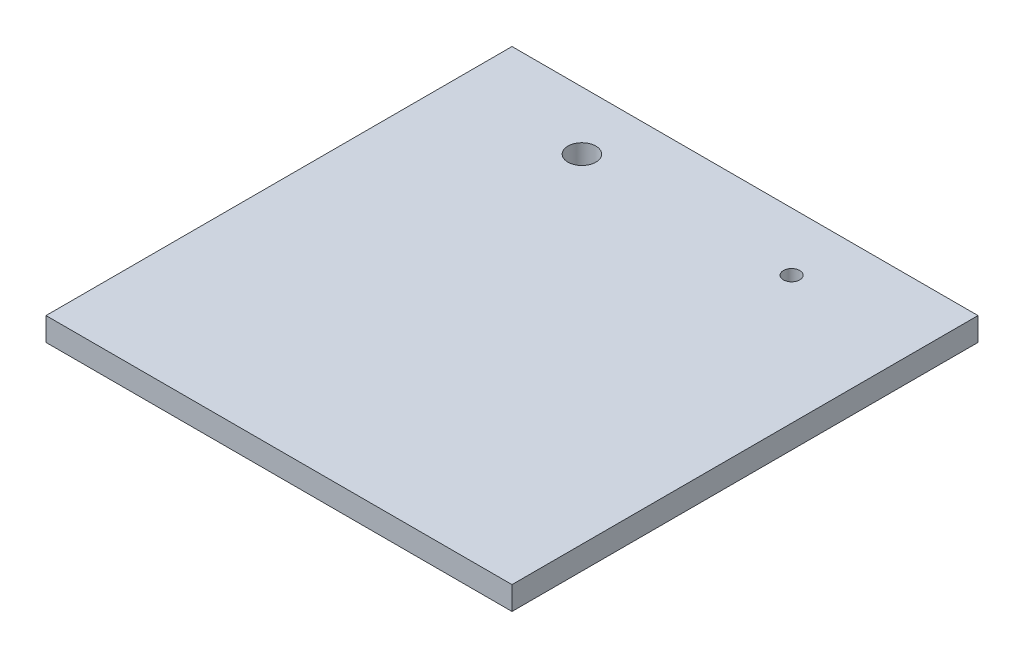
from build123d import *

# Parameters (mm, degrees)
SKETCH1_W           = 200
SKETCH1_H           = 200
BOSS_EXTRUDE1_DEPTH = 10
SKETCH2_R           = 3.5
CUT_EXTRUDE1_DEPTH  = 11
SKETCH3_R           = 6
CUT_EXTRUDE2_DEPTH  = 11


with BuildPart() as part:
    # Sketch1 → Boss-Extrude1 (new body)
    with BuildSketch(Plane(origin=(0, 0, 0), x_dir=(1, 0, 0), z_dir=(0, 1, 0))):
        Rectangle(SKETCH1_W, SKETCH1_H)
    extrude(amount=BOSS_EXTRUDE1_DEPTH)

    # Sketch2 → Cut-Extrude1 (cut, through all)
    with BuildSketch(Plane(origin=(0, 10, 0), x_dir=(1, 0, 0), z_dir=(0, 1, 0))):
        with Locations((45, 75)):
            Circle(SKETCH2_R)
    extrude(amount=-CUT_EXTRUDE1_DEPTH, mode=Mode.SUBTRACT)

    # Sketch3 → Cut-Extrude2 (cut, through all)
    with BuildSketch(Plane(origin=(0, 10, 0), x_dir=(1, 0, 0), z_dir=(0, 1, 0))):
        with Locations((-45, 75)):
            Circle(SKETCH3_R)
    extrude(amount=-CUT_EXTRUDE2_DEPTH, mode=Mode.SUBTRACT)


solid = part.part
